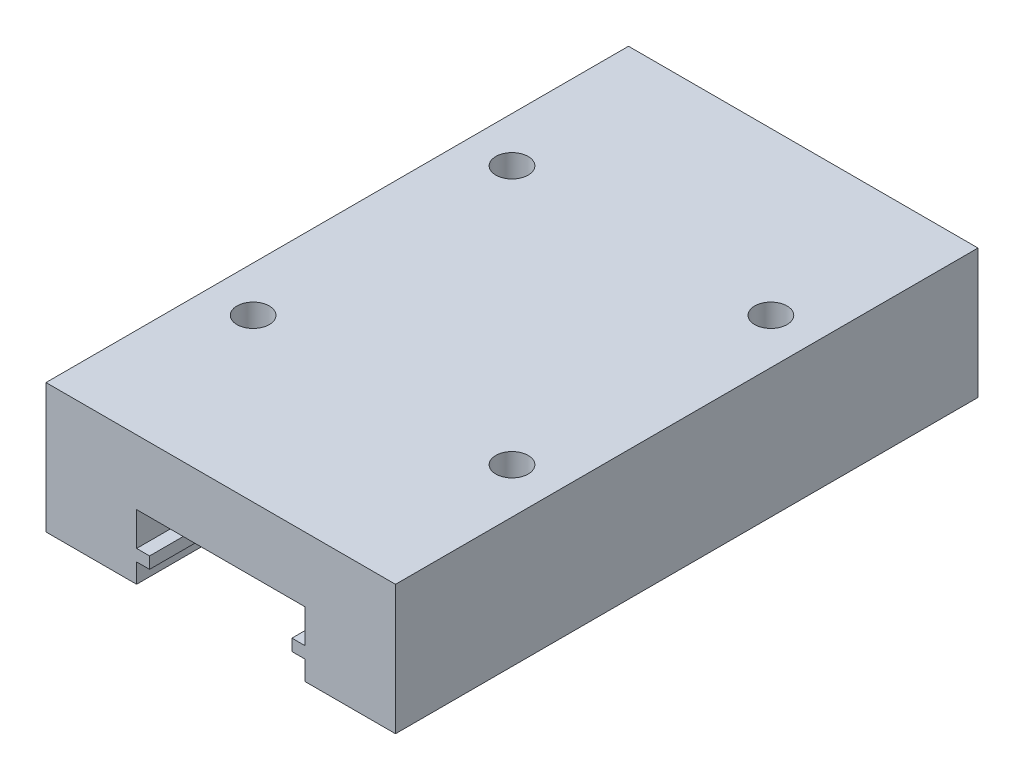
from build123d import *

# Parameters (mm, degrees)
BOSS_EXTRU_1_DEPTH                            = 22.5
TROU_POUR_TARAUDAGE_POUR_TROU_TARAUD_M3_D     = 2.5
TROU_POUR_TARAUDAGE_POUR_TROU_TARAUD_M3_DEPTH = 5
TROU_POUR_TARAUDAGE_POUR_TROU_TARAUD_M3_TIP   = 0.751075774


with BuildPart() as part:
    # Esquisse1 → Boss.-Extru.1 (new body, symmetric)
    with BuildSketch(Plane.XY):
        Polygon((6.5, -5), (13.5, -5), (13.5, 5), (-13.5, 5), (-13.5, -5), (-6.5, -5), (-6.5, -3.5), (-5.5, -3.5), (-5.5, -2.6), (-6.5, -2.6), (-6.5, 0), (6.5, 0), (6.5, -2.6), (5.5, -2.6), (5.5, -3.5), (6.5, -3.5), align=None)
    extrude(amount=BOSS_EXTRU_1_DEPTH, both=True)

    # Trou pour taraudage pour trou taraudé M3x0.51
    with Locations(Plane(origin=(0, 5, 0), x_dir=(1, 0, 0), z_dir=(0, 1, 0))):
        with Locations((-10, 10), (-10, -10), (10, -10), (10, 10)):
            Hole(TROU_POUR_TARAUDAGE_POUR_TROU_TARAUD_M3_D / 2, depth=TROU_POUR_TARAUDAGE_POUR_TROU_TARAUD_M3_DEPTH)
            with Locations((0, 0, -(TROU_POUR_TARAUDAGE_POUR_TROU_TARAUD_M3_DEPTH + TROU_POUR_TARAUDAGE_POUR_TROU_TARAUD_M3_TIP / 2))):  # 118° drill point
                Cone(0, TROU_POUR_TARAUDAGE_POUR_TROU_TARAUD_M3_D / 2, TROU_POUR_TARAUDAGE_POUR_TROU_TARAUD_M3_TIP, mode=Mode.SUBTRACT)


solid = part.part
